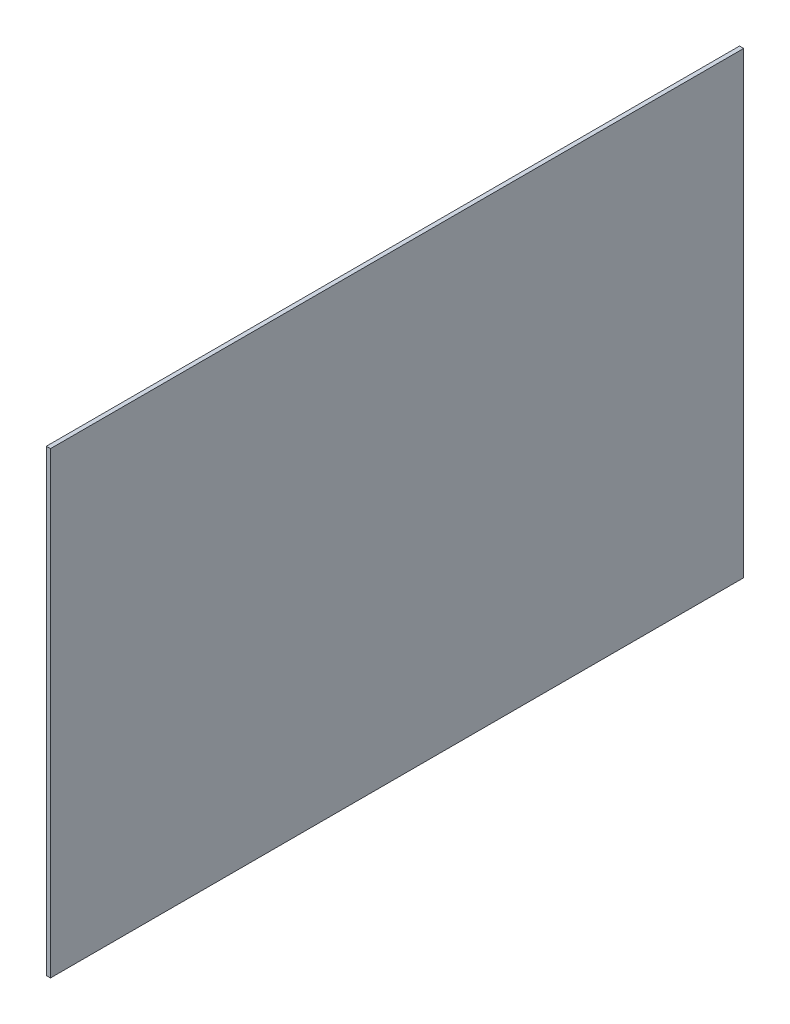
from build123d import *

# Parameters (mm, degrees)
BOSS_EXTRUDE1_DEPTH = 3


with BuildPart() as part:
    # Sketch1 → Boss-Extrude1 (new body)
    with BuildSketch(Plane(origin=(0, 0, 0), x_dir=(0, 0, -1), z_dir=(1, 0, 0))):
        Polygon((250, 145.327172392), (250, 165.327172392), (-250, 165.327172392), (-250, -165.327172392), (250, -165.327172392), align=None)
    extrude(amount=BOSS_EXTRUDE1_DEPTH)


solid = part.part
